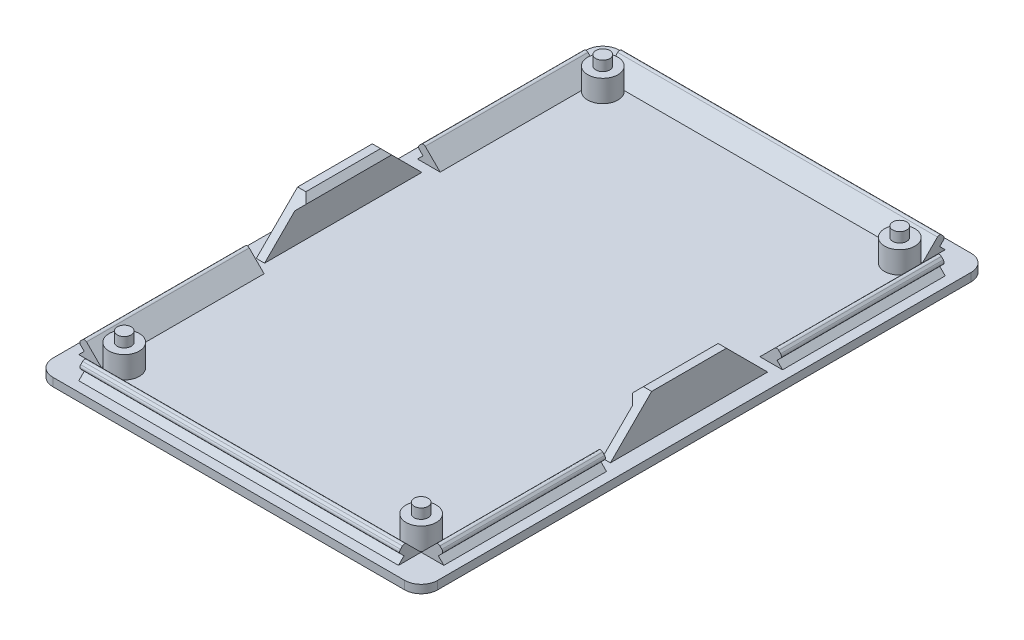
from build123d import *

# Parameters (mm, degrees)
EDIT_GLOBAL_VARIABLE_WITH_PCB_DIMENSIONS_W = 69.96
EDIT_GLOBAL_VARIABLE_WITH_PCB_DIMENSIONS_H = 102.98
BOSS_EXTRUDE1_DEPTH                        = 1.5
FILLET1_R                                  = 3
BOSS_EXTRUDE2_DEPTH                        = 91.1374
BOSS_EXTRUDE3_DEPTH                        = 91.1374
BOSS_EXTRUDE4_DEPTH                        = 58.1174
BOSS_EXTRUDE5_DEPTH                        = 58.1174
FILLET2_R                                  = 0.5
SKETCH7_W                                  = 32
SKETCH7_H                                  = 2.853553391
CUT_EXTRUDE1_DEPTH                         = 35.98
CUT_EXTRUDE1_DEPTH_BACK                    = 35.98
SKETCH8_R                                  = 2.75
BOSS_EXTRUDE6_DEPTH                        = 4
SKETCH11_W                                 = 1.5
SKETCH11_H                                 = 7.5002
BOSS_EXTRUDE8_DEPTH                        = 14.29325
BOSS_EXTRUDE9_DEPTH                        = 14.29325
CHAMFER1_SIZE                              = 7.5
SKETCH10_R                                 = 1.27
BOSS_EXTRUDE10_DEPTH                       = 1.8002


with BuildPart() as part:
    # EDIT GLOBAL VARIABLE WITH PCB DIMENSIONS → Boss-Extrude1 (new body)
    with BuildSketch(Plane(origin=(0, 0, 0), x_dir=(1, 0, 0), z_dir=(0, 1, 0))):
        Rectangle(EDIT_GLOBAL_VARIABLE_WITH_PCB_DIMENSIONS_W, EDIT_GLOBAL_VARIABLE_WITH_PCB_DIMENSIONS_H)
    extrude(amount=BOSS_EXTRUDE1_DEPTH)

    # Fillet1
    fillet1_edges = [part.edges().sort_by_distance(p)[0] for p in [
        (34.98, 0.75, 51.49),
        (-34.98, 0.75, 51.49),
        (-34.98, 0.75, -51.49),
        (34.98, 0.75, -51.49),
    ]]
    fillet(fillet1_edges, radius=FILLET1_R)

    # Sketch2 → Boss-Extrude2 (add)
    with BuildSketch(Plane.XY.offset(45.5687)):
        Polygon((33.18, 1.5), (29.058679656, 1.5), (32.119339828, 4.560660172), (33.18, 3.5), (32.18, 2.5), align=None)
    extrude(amount=-BOSS_EXTRUDE2_DEPTH)

    # Sketch3 → Boss-Extrude3 (add)
    with BuildSketch(Plane.XY.offset(45.5687)):
        Polygon((-33.18, 1.5), (-29.058679656, 1.5), (-32.119339828, 4.560660172), (-33.18, 3.5), (-32.18, 2.5), align=None)
    extrude(amount=-BOSS_EXTRUDE3_DEPTH)

    # Sketch4 → Boss-Extrude4 (add)
    with BuildSketch(Plane.ZY.offset(29.0587)):
        Polygon((-49.69, 1.5), (-45.568679656, 1.5), (-48.629339828, 4.560660172), (-49.69, 3.5), (-48.69, 2.5), align=None)
    extrude(amount=-BOSS_EXTRUDE4_DEPTH)

    # Sketch5 → Boss-Extrude5 (add)
    with BuildSketch(Plane.ZY.offset(29.0587)):
        Polygon((45.568679656, 1.5), (49.69, 1.5), (48.69, 2.5), (49.69, 3.5), (48.629339828, 4.560660172), align=None)
    extrude(amount=-BOSS_EXTRUDE5_DEPTH)

    # Fillet2
    fillet2_edges = [part.edges().sort_by_distance(p)[0] for p in [
        (33.18, 3.5, 0),
        (32.119339828, 4.560660172, 0),
        (-32.119339828, 4.560660172, 0),
        (-33.18, 3.5, 0),
        (0, 4.560660172, -48.629339828),
        (0, 3.5, -49.69),
        (0, 3.5, 49.69),
        (0, 4.560660172, 48.629339828),
    ]]
    fillet(fillet2_edges, radius=FILLET2_R)

    # Sketch7 → Cut-Extrude1 (cut, two sides)
    with BuildSketch(Plane(origin=(0, 0, 0), x_dir=(0, 0, -1), z_dir=(1, 0, 0))) as cut_extrude1_sk:
        with Locations((0, 2.926776696)):
            Rectangle(SKETCH7_W, SKETCH7_H)
    extrude(amount=CUT_EXTRUDE1_DEPTH, mode=Mode.SUBTRACT)
    extrude(cut_extrude1_sk.sketch, amount=-CUT_EXTRUDE1_DEPTH_BACK, mode=Mode.SUBTRACT)

    # Sketch8 → Boss-Extrude6 (add)
    with BuildSketch(Plane(origin=(0, 1.5, 0), x_dir=(1, 0, 0), z_dir=(0, 1, 0))):
        with Locations(Location((-26.98732474, 43.49732474, 0), (0, 0, 131.129923219))):  # turned: the seam where the file's is
            Circle(SKETCH8_R)
        with Locations(Location((26.98732474, 43.49732474, 0), (0, 0, 131.129923219))):  # turned: the seam where the file's is
            Circle(SKETCH8_R)
        with Locations(Location((-26.98732474, -43.49732474, 0), (0, 0, 138.870076781))):  # turned: the seam where the file's is
            Circle(SKETCH8_R)
        with Locations(Location((26.98732474, -43.49732474, 0), (0, 0, 41.129923219))):  # turned: the seam where the file's is
            Circle(SKETCH8_R)
    extrude(amount=BOSS_EXTRUDE6_DEPTH)

    # Sketch11 → Boss-Extrude8 (add, symmetric)
    with BuildSketch(Plane.XY):
        with Locations((-31.43, 5.2501)):
            Rectangle(SKETCH11_W, SKETCH11_H)
        with Locations((31.43, 5.2501)):
            Rectangle(SKETCH11_W, SKETCH11_H)
    extrude(amount=BOSS_EXTRUDE8_DEPTH, both=True)

    # Sketch12 → Boss-Extrude9 (add, symmetric)
    with BuildSketch(Plane.XY):
        Polygon((30.68, 9.0002), (30.68, 7.0002), (29.68, 8.0002), align=None)
        Polygon((-30.68, 9.0002), (-30.68, 7.0002), (-29.68, 8.0002), align=None)
    extrude(amount=BOSS_EXTRUDE9_DEPTH, both=True)

    # Chamfer1
    chamfer1_edges = [part.edges().sort_by_distance(p)[0] for p in [
        (31.43, 9.0002, -14.29325),
        (31.43, 9.0002, 14.29325),
        (-31.43, 9.0002, -14.29325),
        (-31.43, 9.0002, 14.29325),
    ]]
    chamfer(chamfer1_edges, length=CHAMFER1_SIZE)

    # Sketch10 → Boss-Extrude10 (add)
    with BuildSketch(Plane(origin=(0, 5.5, 0), x_dir=(1, 0, 0), z_dir=(0, 1, 0))):
        with Locations(Location((-26.98732474, 43.49732474, 0), (0, 0, 270))):  # turned: the seam where the file's is
            Circle(SKETCH10_R)
        with Locations(Location((26.98732474, 43.49732474, 0), (0, 0, 270))):  # turned: the seam where the file's is
            Circle(SKETCH10_R)
        with Locations(Location((26.98732474, -43.49732474, 0), (0, 0, 270))):  # turned: the seam where the file's is
            Circle(SKETCH10_R)
        with Locations(Location((-26.98732474, -43.49732474, 0), (0, 0, 270))):  # turned: the seam where the file's is
            Circle(SKETCH10_R)
    extrude(amount=BOSS_EXTRUDE10_DEPTH)


solid = part.part
